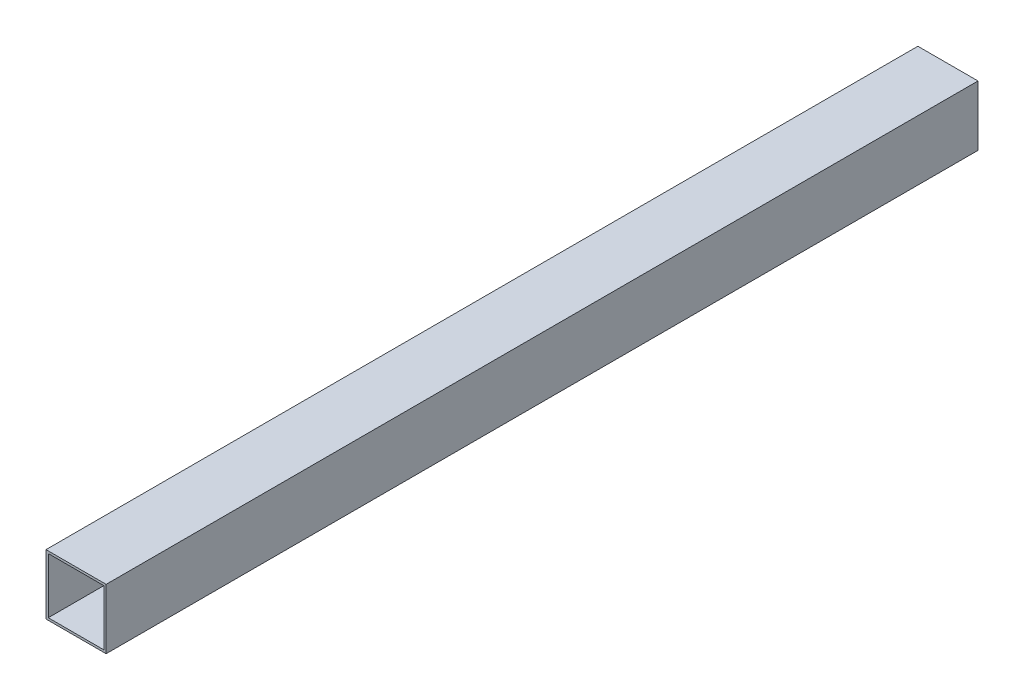
from build123d import *

# Parameters (mm, degrees)
ESQUISSE1_W        = 40
ESQUISSE1_H        = 40
ESQUISSE1_W_2      = 37
ESQUISSE1_H_2      = 37
BOSS_EXTRU_1_DEPTH = 580


with BuildPart() as part:
    # Esquisse1 → Boss.-Extru.1 (new body)
    with BuildSketch(Plane.XY):
        Rectangle(ESQUISSE1_W, ESQUISSE1_H)
        Rectangle(ESQUISSE1_W_2, ESQUISSE1_H_2, mode=Mode.SUBTRACT)
    extrude(amount=BOSS_EXTRU_1_DEPTH)


solid = part.part
